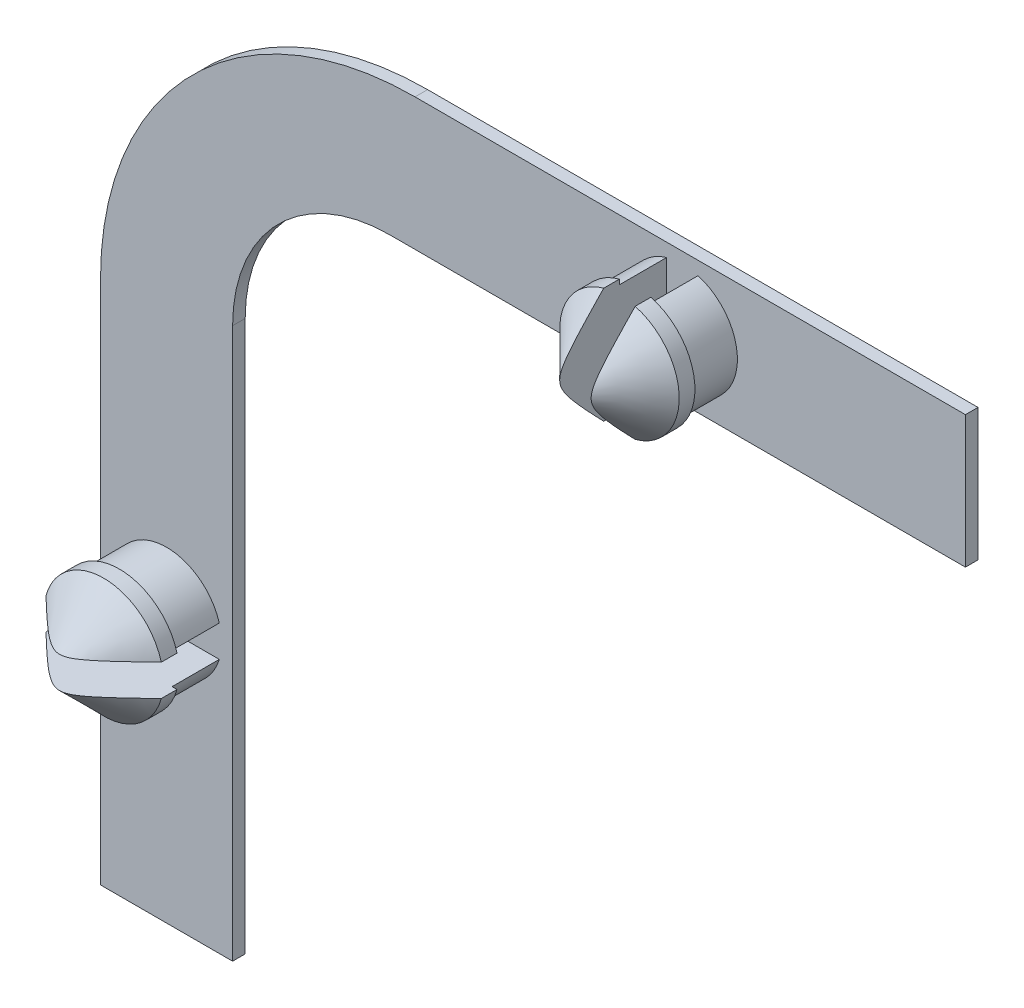
from build123d import *

# Parameters (mm, degrees)
SKICA2_W                 = 27.5
SKICA2_H                 = 4.2
P_IDAT_VYSUNUT_M2_DEPTH  = 0.4
SKICA3_R                 = 1.75
P_IDAT_VYSUNUT_M3_DEPTH  = 1.5
SKICA5_R                 = 1.9
P_IDAT_VYSUNUT_M5_DEPTH  = 2
ZKOSEN_2_SIZE            = 1.5
SKICA7_W                 = 1
SKICA7_H                 = 5
ODEBRAT_VYSUNUT_M1_DEPTH = 3.5
SKICA8_W                 = 4.2
SKICA8_H                 = 22.5
P_IDAT_VYSUNUT_M6_DEPTH  = 0.4
SKICA9_R                 = 1.75
P_IDAT_VYSUNUT_M7_DEPTH  = 1.5
SKICA10_R                = 1.9
P_IDAT_VYSUNUT_M8_DEPTH  = 2
ZKOSEN_3_SIZE            = 1.5
SKICA12_W                = 5
SKICA12_H                = 1
ODEBRAT_VYSUNUT_M2_DEPTH = 3.5
ZAOBLIT1_R               = 5
ZAOBLIT2_R               = 10


with BuildPart() as part:
    # Skica2 → Přidat vysunutím2 (new body)
    with BuildSketch(Plane.XY):
        Rectangle(SKICA2_W, SKICA2_H)
    extrude(amount=P_IDAT_VYSUNUT_M2_DEPTH)

    # Skica3 → Přidat vysunutím3 (add)
    with BuildSketch(Plane.XY.offset(0.4)):
        with Locations((4.75, 0)):
            Circle(SKICA3_R)
    extrude(amount=P_IDAT_VYSUNUT_M3_DEPTH)

    # Skica5 → Přidat vysunutím5 (add)
    with BuildSketch(Plane.XY.offset(1.9)):
        with Locations((4.75, 0)):
            Circle(SKICA5_R)
    extrude(amount=P_IDAT_VYSUNUT_M5_DEPTH)

    # Zkosení2
    zkosen_2_edges = [part.edges().sort_by_distance(p)[0] for p in [
        (2.85, 0, 3.9),
    ]]
    chamfer(zkosen_2_edges, length=ZKOSEN_2_SIZE)

    # Skica7 → Odebrat vysunutím1 (cut)
    with BuildSketch(Plane.XY.offset(3.9)):
        with Locations((4.75, 0)):
            Rectangle(SKICA7_W, SKICA7_H)
    extrude(amount=-ODEBRAT_VYSUNUT_M1_DEPTH, mode=Mode.SUBTRACT)

    # Skica8 → Přidat vysunutím6 (add)
    with BuildSketch(Plane(origin=(0, 0, 0), x_dir=(-1, 0, 0), z_dir=(0, 0, -1))):
        with Locations((11.65, -13.35)):
            Rectangle(SKICA8_W, SKICA8_H)
    extrude(amount=-P_IDAT_VYSUNUT_M6_DEPTH)

    # Skica9 → Přidat vysunutím7 (add)
    with BuildSketch(Plane.XY.offset(0.4)):
        with Locations((-11.65, -16)):
            Circle(SKICA9_R)
    extrude(amount=P_IDAT_VYSUNUT_M7_DEPTH)

    # Skica10 → Přidat vysunutím8 (add)
    with BuildSketch(Plane.XY.offset(1.9)):
        with Locations((-11.65, -16)):
            Circle(SKICA10_R)
    extrude(amount=P_IDAT_VYSUNUT_M8_DEPTH)

    # Zkosení3
    zkosen_3_edges = [part.edges().sort_by_distance(p)[0] for p in [
        (-13.55, -16, 3.9),
    ]]
    chamfer(zkosen_3_edges, length=ZKOSEN_3_SIZE)

    # Skica12 → Odebrat vysunutím2 (cut)
    with BuildSketch(Plane.XY.offset(3.9)):
        with Locations((-11.65, -16)):
            Rectangle(SKICA12_W, SKICA12_H)
    extrude(amount=-ODEBRAT_VYSUNUT_M2_DEPTH, mode=Mode.SUBTRACT)

    # Zaoblit1
    zaoblit1_edges = [part.edges().sort_by_distance(p)[0] for p in [
        (-9.55, -2.1, 0.2),
    ]]
    fillet(zaoblit1_edges, radius=ZAOBLIT1_R)

    # Zaoblit2
    zaoblit2_edges = [part.edges().sort_by_distance(p)[0] for p in [
        (-13.75, 2.1, 0.2),
    ]]
    fillet(zaoblit2_edges, radius=ZAOBLIT2_R)


solid = part.part
